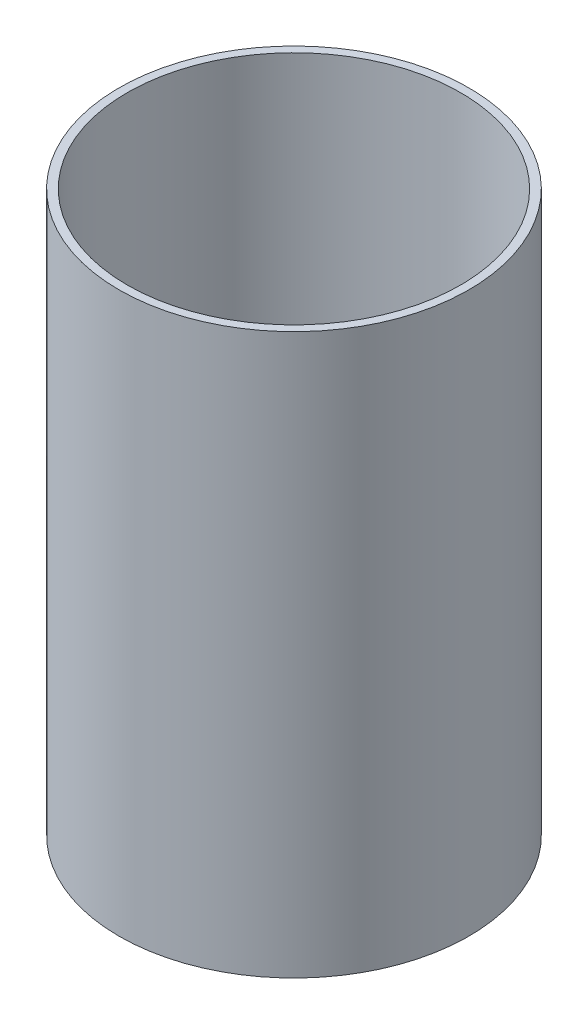
from build123d import *

# Parameters (mm, degrees)
SKETCH1_R           = 63.5
SKETCH1_R_2         = 60.5028
BOSS_EXTRUDE1_DEPTH = 203.2


with BuildPart() as part:
    # Sketch1 → Boss-Extrude1 (new body)
    with BuildSketch(Plane(origin=(0, 0, 0), x_dir=(1, 0, 0), z_dir=(0, 1, 0))):
        Circle(SKETCH1_R)
        Circle(SKETCH1_R_2, mode=Mode.SUBTRACT)
    extrude(amount=BOSS_EXTRUDE1_DEPTH)


solid = part.part
